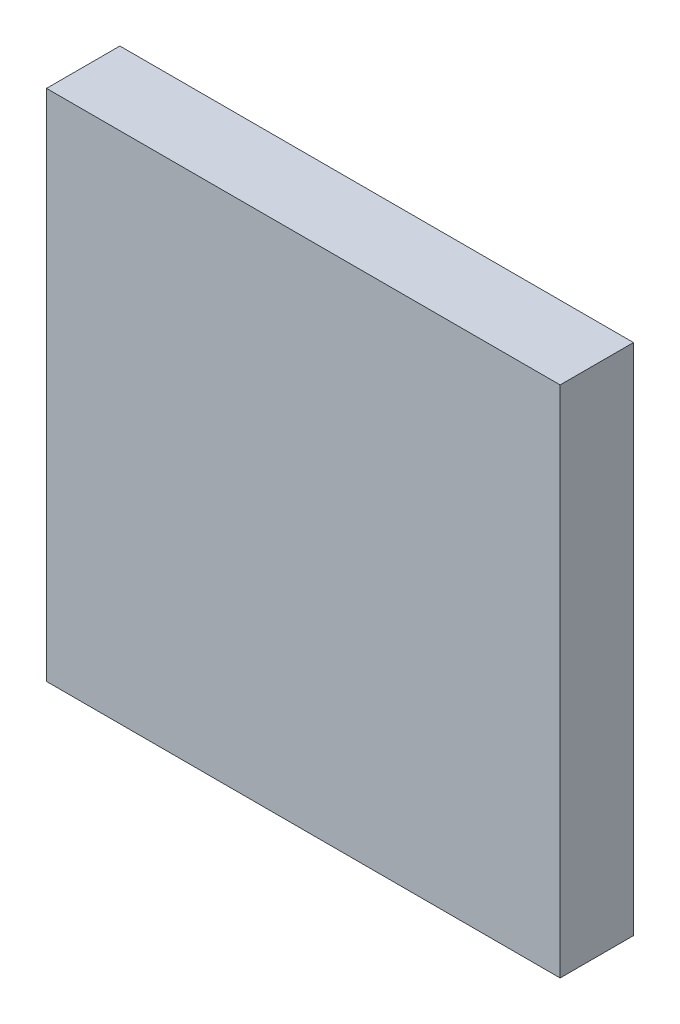
from build123d import *

# Parameters (mm, degrees)
ESQUISSE1_W        = 7
ESQUISSE1_H        = 7
BOSS_EXTRU_1_DEPTH = 1


with BuildPart() as part:
    # Esquisse1 → Boss.-Extru.1 (new body)
    with BuildSketch(Plane.XY):
        Rectangle(ESQUISSE1_W, ESQUISSE1_H)
    extrude(amount=BOSS_EXTRU_1_DEPTH)


solid = part.part
